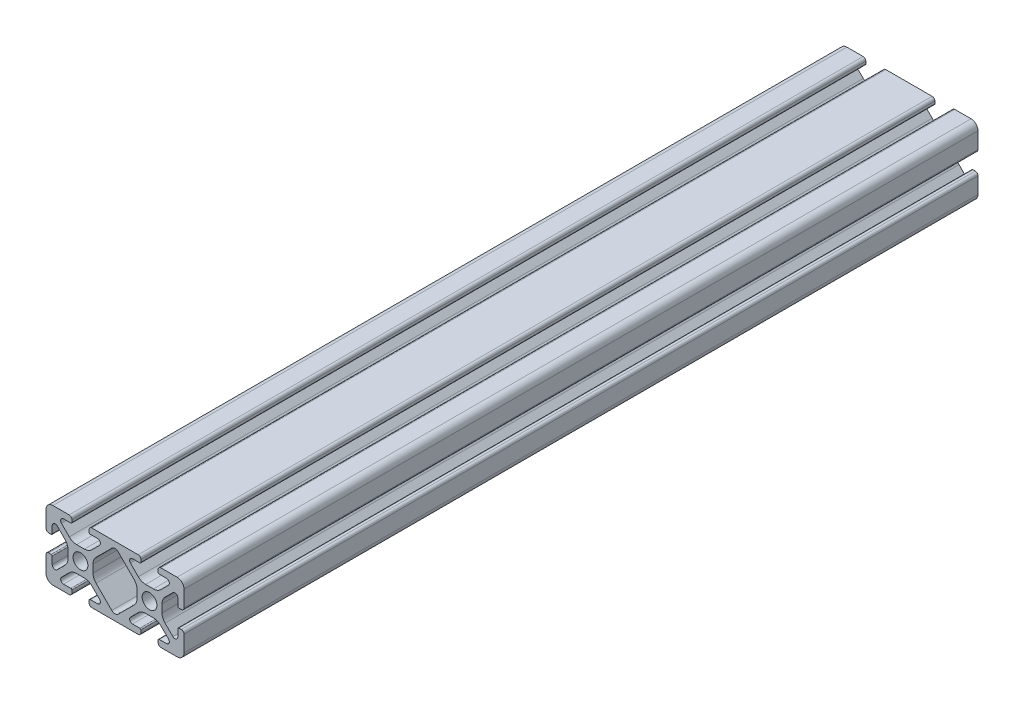
from build123d import *

# Parameters (mm, degrees)
SKETCH1_R           = 2.1463
BOSS_EXTRUDE1_DEPTH = 115


with BuildPart() as part:
    # Sketch1 → Boss-Extrude1 (new body, symmetric)
    with BuildSketch(Plane.XY):
        with BuildLine():
            Line((-19.9898, 7.9883), (-19.9898, 3.2893))
            ThreePointArc((-19.9898, 3.2893), (-19.75917588, 2.73252412), (-19.2024, 2.5019))
            Line((-19.2024, 2.5019), (-18.4912, 2.5019))
            ThreePointArc((-18.4912, 2.5019), (-18.275673853, 2.591173853), (-18.1864, 2.8067))
            Line((-18.1864, 2.8067), (-18.1864, 4.9149))
            ThreePointArc((-18.1864, 4.9149), (-17.668965253, 5.689295824), (-16.755503096, 5.507596904))
            Line((-16.755503096, 5.507596904), (-14.500665747, 3.252759555))
            ThreePointArc((-14.500665747, 3.252759555), (-13.850954457, 2.280397894), (-13.622806192, 1.133419111))
            Line((-13.622806192, 1.133419111), (-13.622806192, -1.133419111))
            ThreePointArc((-13.622806192, -1.133419111), (-13.850954457, -2.280397894), (-14.500665747, -3.252759555))
            Line((-14.500665747, -3.252759555), (-16.755503096, -5.507596904))
            ThreePointArc((-16.755503096, -5.507596904), (-17.668965253, -5.689295824), (-18.1864, -4.9149))
            Line((-18.1864, -4.9149), (-18.1864, -2.8067))
            ThreePointArc((-18.1864, -2.8067), (-18.275673853, -2.591173853), (-18.4912, -2.5019))
            Line((-18.4912, -2.5019), (-19.2024, -2.5019))
            ThreePointArc((-19.2024, -2.5019), (-19.75917588, -2.73252412), (-19.9898, -3.2893))
            Line((-19.9898, -3.2893), (-19.9898, -7.9883))
            ThreePointArc((-19.9898, -7.9883), (-19.402080467, -9.407180467), (-17.9832, -9.9949))
            Line((-17.9832, -9.9949), (-13.2842, -9.9949))
            ThreePointArc((-13.2842, -9.9949), (-12.72742412, -9.76427588), (-12.4968, -9.2075))
            Line((-12.4968, -9.2075), (-12.4968, -8.4963))
            ThreePointArc((-12.4968, -8.4963), (-12.586073853, -8.280773853), (-12.8016, -8.1915))
            Line((-12.8016, -8.1915), (-14.9098, -8.1915))
            ThreePointArc((-14.9098, -8.1915), (-15.684195824, -7.674065253), (-15.502496904, -6.760603096))
            Line((-15.502496904, -6.760603096), (-13.247659555, -4.505765747))
            ThreePointArc((-13.247659555, -4.505765747), (-12.275297894, -3.856054457), (-11.128319111, -3.627906192))
            Line((-11.128319111, -3.627906192), (-8.861480889, -3.627906192))
            ThreePointArc((-8.861480889, -3.627906192), (-7.714502106, -3.856054457), (-6.742140445, -4.505765747))
            Line((-6.742140445, -4.505765747), (-4.487303096, -6.760603096))
            ThreePointArc((-4.487303096, -6.760603096), (-4.305604176, -7.674065253), (-5.08, -8.1915))
            Line((-5.08, -8.1915), (-7.1882, -8.1915))
            ThreePointArc((-7.1882, -8.1915), (-7.403726147, -8.280773853), (-7.493, -8.4963))
            Line((-7.493, -8.4963), (-7.493, -9.2075))
            ThreePointArc((-7.493, -9.2075), (-7.26237588, -9.76427588), (-6.7056, -9.9949))
            Line((-6.7056, -9.9949), (0, -9.9949))
            Line((0, -9.9949), (6.7056, -9.9949))
            ThreePointArc((6.7056, -9.9949), (7.26237588, -9.76427588), (7.493, -9.2075))
            Line((7.493, -9.2075), (7.493, -8.4963))
            ThreePointArc((7.493, -8.4963), (7.403726147, -8.280773853), (7.1882, -8.1915))
            Line((7.1882, -8.1915), (5.08, -8.1915))
            ThreePointArc((5.08, -8.1915), (4.305604176, -7.674065253), (4.487303096, -6.760603096))
            Line((4.487303096, -6.760603096), (6.742140445, -4.505765747))
            ThreePointArc((6.742140445, -4.505765747), (7.714502106, -3.856054457), (8.861480889, -3.627906192))
            Line((8.861480889, -3.627906192), (11.128319111, -3.627906192))
            ThreePointArc((11.128319111, -3.627906192), (12.275297894, -3.856054457), (13.247659555, -4.505765747))
            Line((13.247659555, -4.505765747), (15.502496904, -6.760603096))
            ThreePointArc((15.502496904, -6.760603096), (15.684195824, -7.674065253), (14.9098, -8.1915))
            Line((14.9098, -8.1915), (12.8016, -8.1915))
            ThreePointArc((12.8016, -8.1915), (12.586073853, -8.280773853), (12.4968, -8.4963))
            Line((12.4968, -8.4963), (12.4968, -9.2075))
            ThreePointArc((12.4968, -9.2075), (12.72742412, -9.76427588), (13.2842, -9.9949))
            Line((13.2842, -9.9949), (17.9832, -9.9949))
            ThreePointArc((17.9832, -9.9949), (19.402080467, -9.407180467), (19.9898, -7.9883))
            Line((19.9898, -7.9883), (19.9898, -3.2893))
            ThreePointArc((19.9898, -3.2893), (19.75917588, -2.73252412), (19.2024, -2.5019))
            Line((19.2024, -2.5019), (18.4912, -2.5019))
            ThreePointArc((18.4912, -2.5019), (18.275673853, -2.591173853), (18.1864, -2.8067))
            Line((18.1864, -2.8067), (18.1864, -4.9149))
            ThreePointArc((18.1864, -4.9149), (17.668965253, -5.689295824), (16.755503096, -5.507596904))
            Line((16.755503096, -5.507596904), (14.500665747, -3.252759555))
            ThreePointArc((14.500665747, -3.252759555), (13.850954457, -2.280397894), (13.622806192, -1.133419111))
            Line((13.622806192, -1.133419111), (13.622806192, 1.133419111))
            ThreePointArc((13.622806192, 1.133419111), (13.850954457, 2.280397894), (14.500665747, 3.252759555))
            Line((14.500665747, 3.252759555), (16.755503096, 5.507596904))
            ThreePointArc((16.755503096, 5.507596904), (17.668965253, 5.689295824), (18.1864, 4.9149))
            Line((18.1864, 4.9149), (18.1864, 2.8067))
            ThreePointArc((18.1864, 2.8067), (18.275673853, 2.591173853), (18.4912, 2.5019))
            Line((18.4912, 2.5019), (19.2024, 2.5019))
            ThreePointArc((19.2024, 2.5019), (19.75917588, 2.73252412), (19.9898, 3.2893))
            Line((19.9898, 3.2893), (19.9898, 7.9883))
            ThreePointArc((19.9898, 7.9883), (19.402080467, 9.407180467), (17.9832, 9.9949))
            Line((17.9832, 9.9949), (13.2842, 9.9949))
            ThreePointArc((13.2842, 9.9949), (12.72742412, 9.76427588), (12.4968, 9.2075))
            Line((12.4968, 9.2075), (12.4968, 8.4963))
            ThreePointArc((12.4968, 8.4963), (12.586073853, 8.280773853), (12.8016, 8.1915))
            Line((12.8016, 8.1915), (14.9098, 8.1915))
            ThreePointArc((14.9098, 8.1915), (15.684195824, 7.674065253), (15.502496904, 6.760603096))
            Line((15.502496904, 6.760603096), (13.247659555, 4.505765747))
            ThreePointArc((13.247659555, 4.505765747), (12.275297894, 3.856054457), (11.128319111, 3.627906192))
            Line((11.128319111, 3.627906192), (8.861480889, 3.627906192))
            ThreePointArc((8.861480889, 3.627906192), (7.714502106, 3.856054457), (6.742140445, 4.505765747))
            Line((6.742140445, 4.505765747), (4.487303096, 6.760603096))
            ThreePointArc((4.487303096, 6.760603096), (4.305604176, 7.674065253), (5.08, 8.1915))
            Line((5.08, 8.1915), (7.1882, 8.1915))
            ThreePointArc((7.1882, 8.1915), (7.403726147, 8.280773853), (7.493, 8.4963))
            Line((7.493, 8.4963), (7.493, 9.2075))
            ThreePointArc((7.493, 9.2075), (7.26237588, 9.76427588), (6.7056, 9.9949))
            Line((6.7056, 9.9949), (0, 9.9949))
            Line((0, 9.9949), (-6.7056, 9.9949))
            ThreePointArc((-6.7056, 9.9949), (-7.26237588, 9.76427588), (-7.493, 9.2075))
            Line((-7.493, 9.2075), (-7.493, 8.4963))
            ThreePointArc((-7.493, 8.4963), (-7.403726147, 8.280773853), (-7.1882, 8.1915))
            Line((-7.1882, 8.1915), (-5.08, 8.1915))
            ThreePointArc((-5.08, 8.1915), (-4.305604176, 7.674065253), (-4.487303096, 6.760603096))
            Line((-4.487303096, 6.760603096), (-6.742140445, 4.505765747))
            ThreePointArc((-6.742140445, 4.505765747), (-7.714502106, 3.856054457), (-8.861480889, 3.627906192))
            Line((-8.861480889, 3.627906192), (-11.128319111, 3.627906192))
            ThreePointArc((-11.128319111, 3.627906192), (-12.275297894, 3.856054457), (-13.247659555, 4.505765747))
            Line((-13.247659555, 4.505765747), (-15.502496904, 6.760603096))
            ThreePointArc((-15.502496904, 6.760603096), (-15.684195824, 7.674065253), (-14.9098, 8.1915))
            Line((-14.9098, 8.1915), (-12.8016, 8.1915))
            ThreePointArc((-12.8016, 8.1915), (-12.586073853, 8.280773853), (-12.4968, 8.4963))
            Line((-12.4968, 8.4963), (-12.4968, 9.2075))
            ThreePointArc((-12.4968, 9.2075), (-12.72742412, 9.76427588), (-13.2842, 9.9949))
            Line((-13.2842, 9.9949), (-17.9832, 9.9949))
            ThreePointArc((-17.9832, 9.9949), (-19.402080467, 9.407180467), (-19.9898, 7.9883))
        make_face()
        with Locations((-9.9949, 0)):
            Circle(SKETCH1_R, mode=Mode.SUBTRACT)
        with Locations((9.9949, 0)):
            Circle(SKETCH1_R, mode=Mode.SUBTRACT)
        with BuildLine():
            Line((-6.366993808, 1.133419111), (-6.366993808, -1.133419111))
            ThreePointArc((-6.366993808, -1.133419111), (-6.138845543, -2.280397894), (-5.489134253, -3.252759555))
            Line((-5.489134253, -3.252759555), (-0.939581002, -7.802312806))
            ThreePointArc((-0.939581002, -7.802312806), (0, -8.1915), (0.939581002, -7.802312806))
            Line((0.939581002, -7.802312806), (5.489134253, -3.252759555))
            ThreePointArc((5.489134253, -3.252759555), (6.138845543, -2.280397894), (6.366993808, -1.133419111))
            Line((6.366993808, -1.133419111), (6.366993808, 1.133419111))
            ThreePointArc((6.366993808, 1.133419111), (6.138845543, 2.280397894), (5.489134253, 3.252759555))
            Line((5.489134253, 3.252759555), (0.939581002, 7.802312806))
            ThreePointArc((0.939581002, 7.802312806), (0, 8.1915), (-0.939581002, 7.802312806))
            Line((-0.939581002, 7.802312806), (-5.489134253, 3.252759555))
            ThreePointArc((-5.489134253, 3.252759555), (-6.138845543, 2.280397894), (-6.366993808, 1.133419111))
        make_face(mode=Mode.SUBTRACT)
    extrude(amount=BOSS_EXTRUDE1_DEPTH, both=True)


solid = part.part
